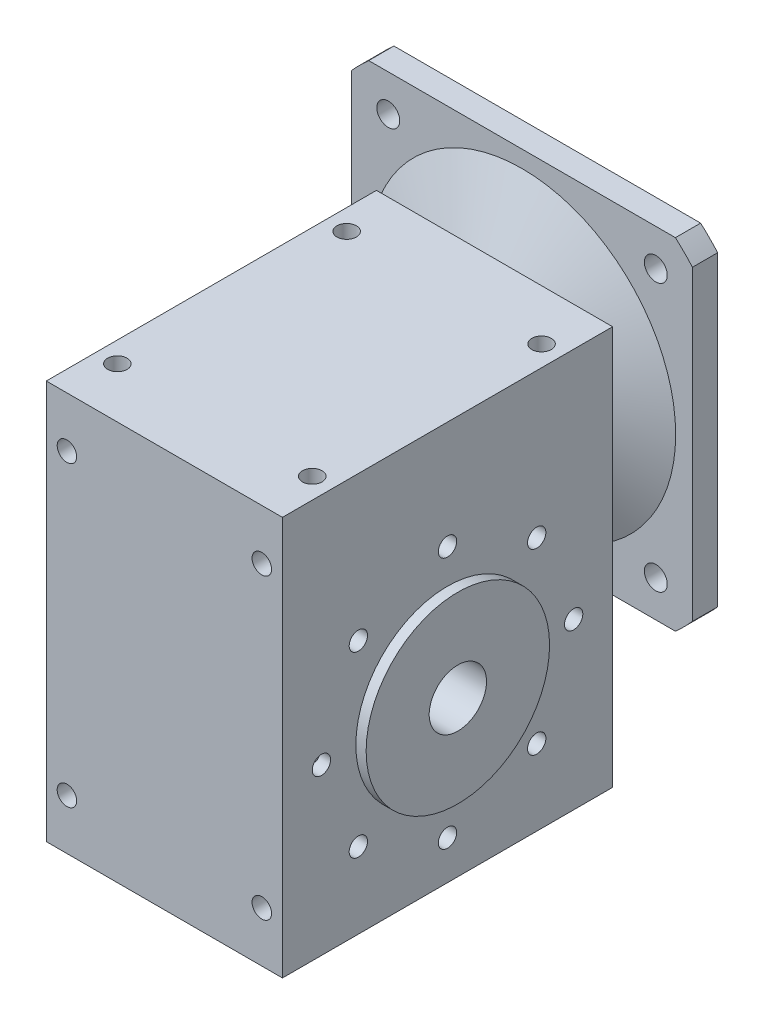
from build123d import *

# Parameters (mm, degrees)
SKETCH_1_W            = 103
SKETCH_1_H            = 144
EXTRUDE_1_DEPTH       = 174
SKETCH_3_R            = 12.5
CUT_EXTRUDE_1_DEPTH   = 104
SKETCH_4_R            = 4
CUT_EXTRUDE_2_DEPTH   = 104
SKETCH_5_R            = 4.25
CUT_EXTRUDE_3_DEPTH   = 175
SKETCH_7_W            = 70
SKETCH_7_H            = 140
CUT_EXTRUDE_4_DEPTH   = 169
SKETCH_8_R            = 40
SKETCH_8_R_2          = 12.5
EXTRUDE_2_DEPTH       = 56
SKETCH_9_R            = 4.25
CUT_EXTRUDE_5_DEPTH   = 144
SKETCH_10_R           = 5
CUT_EXTRUDE_6_DEPTH   = 17
SKETCH_11_OUTSIDE_W   = 272.176
SKETCH_11_OUTSIDE_H   = 307.176
SKETCH_11_OUTSIDE_W_2 = 148.672618896
SKETCH_11_OUTSIDE_H_2 = 148.672618896
CUT_EXTRUDE_7_DEPTH   = 17
SKETCH_14_R           = 17.5
EXTRUDE_3_DEPTH       = 54
SKETCH_12_R           = 11
CUT_EXTRUDE_8_DEPTH   = 52


with BuildPart() as part:
    # Эскиз1 → Бобышка-Вытянуть1 (new body)
    with BuildSketch(Plane(origin=(0, 0, 0), x_dir=(1, 0, 0), z_dir=(0, 1, 0))):
        Rectangle(SKETCH_1_W, SKETCH_1_H)
    extrude(amount=EXTRUDE_1_DEPTH)

    # Эскиз3 → Вырез-Вытянуть1 (cut, through all)
    with BuildSketch(Plane(origin=(51.5, 0, 0), x_dir=(0, 0, -1), z_dir=(1, 0, 0))):
        with Locations((0, 72)):
            Circle(SKETCH_3_R)
    extrude(amount=-CUT_EXTRUDE_1_DEPTH, mode=Mode.SUBTRACT)

    # Эскиз4 → Вырез-Вытянуть2 (cut, through all)
    with BuildSketch(Plane(origin=(51.5, 0, 0), x_dir=(0, 0, -1), z_dir=(1, 0, 0))):
        with Locations((0, 127)):
            Circle(SKETCH_4_R)
        with Locations((38.890872965, 110.890872965)):
            Circle(SKETCH_4_R)
        with Locations((55, 72)):
            Circle(SKETCH_4_R)
        with Locations((38.890872965, 33.109127035)):
            Circle(SKETCH_4_R)
        with Locations((0, 17)):
            Circle(SKETCH_4_R)
        with Locations((-38.890872965, 33.109127035)):
            Circle(SKETCH_4_R)
        with Locations((-55, 72)):
            Circle(SKETCH_4_R)
        with Locations((-38.890872965, 110.890872965)):
            Circle(SKETCH_4_R)
    extrude(amount=-CUT_EXTRUDE_2_DEPTH, mode=Mode.SUBTRACT)

    # Эскиз5 → Вырез-Вытянуть3 (cut, through all)
    with BuildSketch(Plane(origin=(0, 174, 0), x_dir=(1, 0, 0), z_dir=(0, 1, 0))):
        with Locations((-42.5, 50)):
            Circle(SKETCH_5_R)
        with Locations((42.5, 50)):
            Circle(SKETCH_5_R)
        with Locations((42.5, -50)):
            Circle(SKETCH_5_R)
        with Locations((-42.5, -50)):
            Circle(SKETCH_5_R)
    extrude(amount=-CUT_EXTRUDE_3_DEPTH, mode=Mode.SUBTRACT)

    # Эскиз6 → Повернуть1 (revolve)
    with BuildSketch(Plane(origin=(0, 0, 0), x_dir=(0, 0, -1), z_dir=(1, 0, 0))):
        Polygon((89, 146), (72, 146), (72, 174), (84, 202), (84, 235), (95, 235), (95, 200), (89, 200), (79, 176.666666667), (79, 152.5), (89, 152.5), align=None)
    revolve(axis=Axis((0, 135, 119.057986515), (0, 0, -1)))

    # Эскиз7 → Вырез-Вытянуть4 (cut)
    with BuildSketch(Plane.XZ):
        Rectangle(SKETCH_7_W, SKETCH_7_H)
    extrude(amount=-CUT_EXTRUDE_4_DEPTH, mode=Mode.SUBTRACT)

    # Эскиз8 → Бобышка-Вытянуть2 (add, symmetric)
    with BuildSketch(Plane(origin=(0, 0, 0), x_dir=(0, 0, -1), z_dir=(1, 0, 0))):
        with Locations((0, 72)):
            Circle(SKETCH_8_R)
        with Locations((0, 72)):
            Circle(SKETCH_8_R_2, mode=Mode.SUBTRACT)
    extrude(amount=EXTRUDE_2_DEPTH, both=True)

    # Эскиз9 → Вырез-Вытянуть5 (cut)
    with BuildSketch(Plane.XY.offset(72)):
        with Locations((-42.5, 152)):
            Circle(SKETCH_9_R)
        with Locations((42.5, 152)):
            Circle(SKETCH_9_R)
        with Locations((42.5, 22)):
            Circle(SKETCH_9_R)
        with Locations((-42.5, 22)):
            Circle(SKETCH_9_R)
    extrude(amount=-CUT_EXTRUDE_5_DEPTH, mode=Mode.SUBTRACT)

    # Эскиз10 → Вырез-Вытянуть6 (cut)
    with BuildSketch(Plane(origin=(0, 0, -95), x_dir=(-1, 0, 0), z_dir=(0, 0, -1))):
        with Locations((-58.336309448, 193.336309448)):
            Circle(SKETCH_10_R)
        with Locations((58.336309448, 193.336309448)):
            Circle(SKETCH_10_R)
        with Locations((58.336309448, 76.663690552)):
            Circle(SKETCH_10_R)
        with Locations((-58.336309448, 76.663690552)):
            Circle(SKETCH_10_R)
    extrude(amount=-CUT_EXTRUDE_6_DEPTH, mode=Mode.SUBTRACT)

    # Эскиз11 outside → Вырез-Вытянуть7 (cut)
    with BuildSketch(Plane(origin=(0, 0, -95), x_dir=(-1, 0, 0), z_dir=(0, 0, -1))):
        with Locations((0, 117.5)):
            Rectangle(SKETCH_11_OUTSIDE_W, SKETCH_11_OUTSIDE_H)
        with Locations((0, 135)):
            Rectangle(SKETCH_11_OUTSIDE_W_2, SKETCH_11_OUTSIDE_H_2, mode=Mode.SUBTRACT)
    extrude(amount=-CUT_EXTRUDE_7_DEPTH, mode=Mode.SUBTRACT)

    # Эскиз14 → Бобышка-Вытянуть3 (add)
    with BuildSketch(Plane(origin=(0, 0, -89), x_dir=(-1, 0, 0), z_dir=(0, 0, -1))):
        with Locations((0, 135)):
            Circle(SKETCH_14_R)
    extrude(amount=-EXTRUDE_3_DEPTH)

    # Эскиз12 → Вырез-Вытянуть8 (cut)
    with BuildSketch(Plane(origin=(0, 0, -89), x_dir=(-1, 0, 0), z_dir=(0, 0, -1))):
        with Locations((0, 135)):
            Circle(SKETCH_12_R)
    extrude(amount=-CUT_EXTRUDE_8_DEPTH, mode=Mode.SUBTRACT)


solid = part.part
